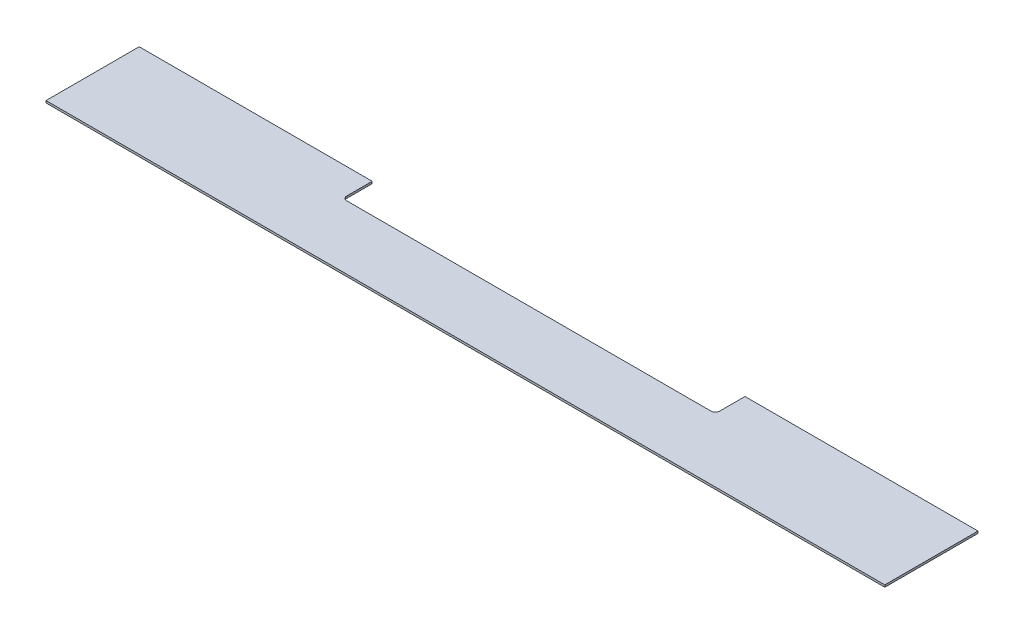
from build123d import *

# Parameters (mm, degrees)
SKETCH1_W           = 1257.3
SKETCH1_H           = 139.7
BOSS_EXTRUDE1_DEPTH = 3.175
SKETCH2_W           = 558.8
SKETCH2_H           = 44.45
CUT_EXTRUDE1_DEPTH  = 4.175
FILLET1_R           = 6.35


with BuildPart() as part:
    # Sketch1 → Boss-Extrude1 (new body)
    with BuildSketch(Plane(origin=(0, 0, 0), x_dir=(1, 0, 0), z_dir=(0, 1, 0))):
        with Locations((628.65, 69.85)):
            Rectangle(SKETCH1_W, SKETCH1_H)
    extrude(amount=BOSS_EXTRUDE1_DEPTH)

    # Sketch2 → Cut-Extrude1 (cut, through all)
    with BuildSketch(Plane(origin=(0, 3.175, 0), x_dir=(1, 0, 0), z_dir=(0, 1, 0))):
        with Locations((628.65, 117.475)):
            Rectangle(SKETCH2_W, SKETCH2_H)
    extrude(amount=-CUT_EXTRUDE1_DEPTH, mode=Mode.SUBTRACT)

    # Fillet1
    fillet1_edges = [part.edges().sort_by_distance(p)[0] for p in [
        (349.25, 1.5875, -95.25),
        (908.05, 1.5875, -95.25),
    ]]
    fillet(fillet1_edges, radius=FILLET1_R)


solid = part.part
